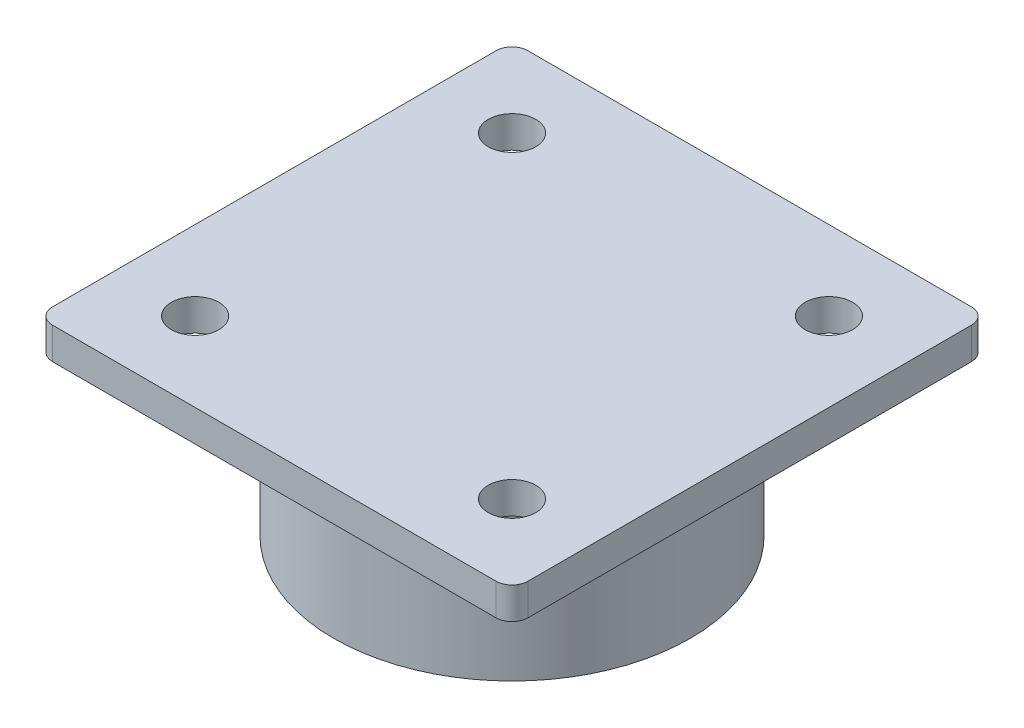
from build123d import *

# Parameters (mm, degrees)
SKETCH2_R           = 3.81
BOSS_EXTRUDE1_DEPTH = 5.08
SKETCH3_R           = 28.575
BOSS_EXTRUDE2_DEPTH = 25.4
SKETCH4_R           = 24.2824
CUT_EXTRUDE1_DEPTH  = 19.05


with BuildPart() as part:
    # Sketch2 → Boss-Extrude1 (new body)
    with BuildSketch(Plane(origin=(0, 0, 0), x_dir=(1, 0, 0), z_dir=(0, 1, 0))):
        with BuildLine():
            Line((-35.56, 38.1), (35.56, 38.1))
            ThreePointArc((35.56, 38.1), (37.356051224, 37.356051224), (38.1, 35.56))
            Line((38.1, 35.56), (38.1, -35.56))
            ThreePointArc((38.1, -35.56), (37.356051224, -37.356051224), (35.56, -38.1))
            Line((35.56, -38.1), (-35.56, -38.1))
            ThreePointArc((-35.56, -38.1), (-37.356051224, -37.356051224), (-38.1, -35.56))
            Line((-38.1, -35.56), (-38.1, 35.56))
            ThreePointArc((-38.1, 35.56), (-37.356051224, 37.356051224), (-35.56, 38.1))
        make_face()
        with Locations((-25.4, 25.4)):
            Circle(SKETCH2_R, mode=Mode.SUBTRACT)
        with Locations((25.4, 25.4)):
            Circle(SKETCH2_R, mode=Mode.SUBTRACT)
        with Locations((25.4, -25.4)):
            Circle(SKETCH2_R, mode=Mode.SUBTRACT)
        with Locations((-25.4, -25.4)):
            Circle(SKETCH2_R, mode=Mode.SUBTRACT)
    extrude(amount=BOSS_EXTRUDE1_DEPTH)

    # Sketch3 → Boss-Extrude2 (add)
    with BuildSketch(Plane.XZ):
        Circle(SKETCH3_R)
    extrude(amount=BOSS_EXTRUDE2_DEPTH)

    # Sketch4 → Cut-Extrude1 (cut)
    with BuildSketch(Plane.XZ.offset(25.4)):
        Circle(SKETCH4_R)
    extrude(amount=-CUT_EXTRUDE1_DEPTH, mode=Mode.SUBTRACT)


solid = part.part
